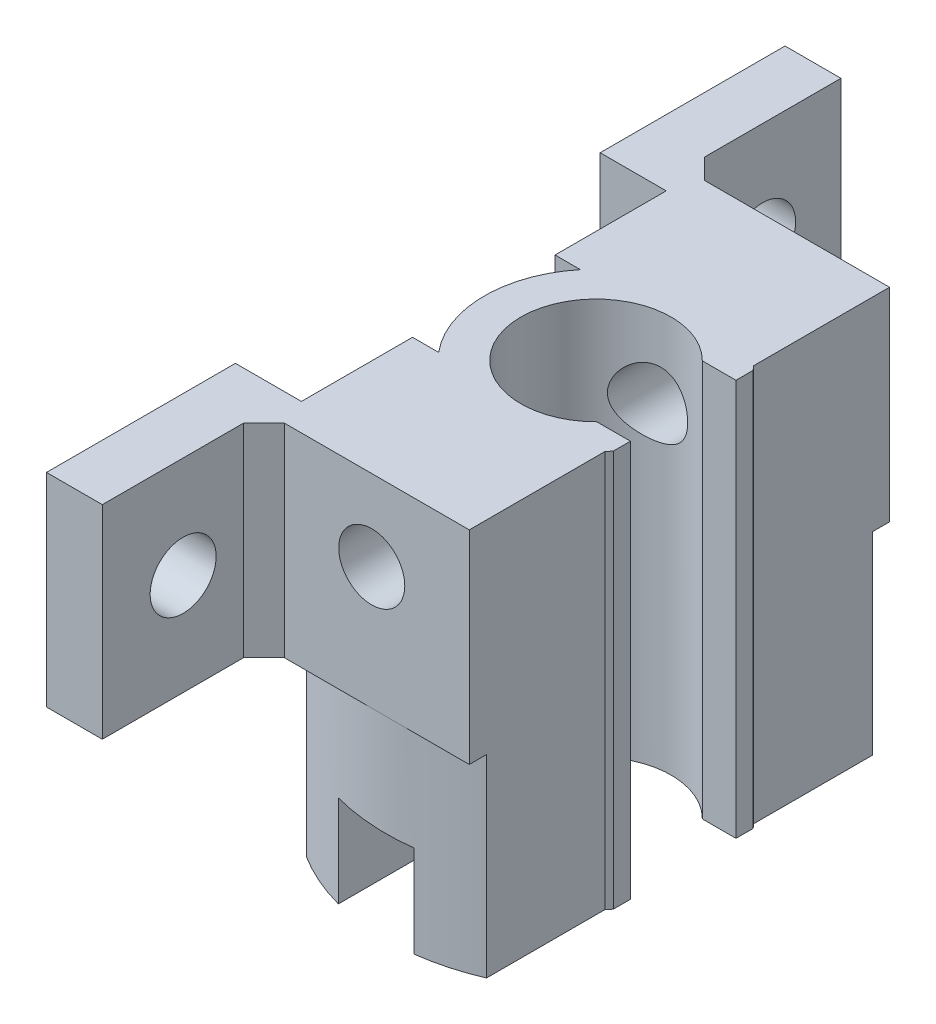
from build123d import *

# Parameters (mm, degrees)
SKETCH_1_R                = 20.68
SKETCH_1_R_2              = 9.68
EXTRUDE_1_DEPTH           = 116.68
SKETCH_11_W               = 27
SKETCH_11_H               = 150
CUT_EXTRUDE_3_DEPTH       = 40
SKETCH_13_W               = 10
SKETCH_13_H               = 128.345013401
CUT_EXTRUDE_7_DEPTH       = 42.68
SKETCH_15_W               = 8
SKETCH_15_H               = 68.68
CUT_EXTRUDE_9_DEPTH       = 48
SKETCH_16_W               = 15.549431524
SKETCH_16_H               = 20
SKETCH_16_W_2             = 15.459431524
EXTRUDE_4_DEPTH           = 19.2
SKETCH_17_W               = 19.20851187
SKETCH_17_H               = 14.03
CUT_EXTRUDE_10_DEPTH      = 20.2
SKETCH_18_R               = 9.59
CUT_EXTRUDE_11_DEPTH      = 117.68
SKETCH_21_R               = 2.985
CUT_EXTRUDE_12_DEPTH      = 55.2
SKETCH_24_R               = 20.59
SKETCH_24_R_2             = 9.59
EXTRUDE_2_DEPTH           = 55.2
CUT_EXTRUDE_13_DEPTH      = 55.2
SKETCH_26_W               = 10.00851187
SKETCH_26_H               = 41.68
CUT_EXTRUDE_15_DEPTH      = 55.2
SKETCH_27_W               = 10
SKETCH_27_H               = 40
CUT_EXTRUDE_16_DEPTH      = 55.2
SKETCH_28_W               = 44.880694938
SKETCH_28_H               = 9.608044066
CUT_EXTRUDE_17_DEPTH      = 12.2
SKETCH_35_W               = 13.53
SKETCH_35_H               = 20
EXTRUDE_10_DEPTH          = 15
EXTRUDE_11_DEPTH          = 15
SKETCH_37_W               = 9
SKETCH_37_H               = 20
EXTRUDE_12_DEPTH          = 20
SKETCH_38_W               = 9
SKETCH_38_H               = 20
EXTRUDE_13_DEPTH          = 20
SKETCH_42_R               = 2.985
CUT_EXTRUDE_21_DEPTH      = 20
CUT_EXTRUDE_23_DEPTH      = 129.465
SKETCH_45_W               = 3
SKETCH_45_H               = 20
EXTRUDE_14_DEPTH          = 30
SKETCH_46_W               = 3
SKETCH_46_H               = 20
EXTRUDE_15_DEPTH          = 30
SKETCH_47_W               = 33.078221107
SKETCH_47_H               = 20
EXTRUDE_16_DEPTH          = 50
SKETCH_48_W               = 30
SKETCH_48_H               = 20
EXTRUDE_17_DEPTH          = 50
SKETCH_50_W               = 50
SKETCH_50_H               = 20
EXTRUDE_18_DEPTH          = 1
SKETCH_51_W               = 50
SKETCH_51_H               = 20
EXTRUDE_19_DEPTH          = 1
SKETCH_52_W               = 53
SKETCH_52_H               = 14
CUT_EXTRUDE_24_DEPTH      = 129.465
SKETCH_53_W               = 53
SKETCH_53_H               = 14
CUT_EXTRUDE_25_DEPTH      = 129.465
SKETCH_54_W               = 40
SKETCH_54_H               = 73.27
CUT_EXTRUDE_26_DEPTH      = 129.465
SKETCH_56_W               = 13.00851187
SKETCH_56_H               = 20
EXTRUDE_21_DEPTH          = 3.08
SKETCH_58_W               = 44.672014854
SKETCH_58_H               = 95.939897673
CUT_EXTRUDE_28_DEPTH      = 90.76
SKETCH_59_R               = 9.7
CUT_EXTRUDE_29_DEPTH      = 40.048276961
SKETCH_60_W               = 6.504255935
SKETCH_60_H               = 76.35
CUT_EXTRUDE_30_DEPTH      = 40.048276961
CUT_EXTRUDE_32_DEPTH      = 20
SKETCH_64_W               = 16.20851187
SKETCH_64_H               = 0.09
EXTRUDE_22_DEPTH          = 20
SKETCH_65_W               = 3.495744065
SKETCH_65_H               = 3.26
CUT_EXTRUDE_33_DEPTH      = 40.048276961
SKETCH_66_W               = 3.495744065
SKETCH_66_H               = 1.776778893
SKETCH_66_W_2             = 3.503635083
SKETCH_66_H_2             = 1.775
EXTRUDE_23_DEPTH          = 20.2
SKETCH_68_W               = 6.504255935
SKETCH_68_H               = 3.66
CUT_EXTRUDE_34_DEPTH      = 20
SKETCH_69_R               = 2.985
CUT_EXTRUDE_35_DEPTH      = 7.504255935
SKETCH_70_R               = 2.985
CUT_EXTRUDE_36_DEPTH      = 17
SKETCH_71_W               = 18.595
SKETCH_71_H               = 20
SKETCH_71_W_2             = 18.195
SKETCH_71_H_2             = 20.0404814
EXTRUDE_24_DEPTH          = 10
SKETCH_72_R               = 3.05
CUT_EXTRUDE_37_DEPTH      = 17.495744065
SKETCH_73_W               = 4
SKETCH_73_H               = 15.42
CUT_EXTRUDE_39_DEPTH      = 40.048276961
SKETCH_74_W               = 4
SKETCH_74_H               = 15.91
CUT_EXTRUDE_40_DEPTH      = 40.048276961
EXTRUDE_25_DEPTH          = 20
SKETCH_77_W               = 7
SKETCH_77_H               = 72.69
CUT_EXTRUDE_41_DEPTH      = 40.048276961
SKETCH_78_R               = 3.25
CUT_EXTRUDE_42_DEPTH      = 87.1
SKETCH_79_R               = 3.25
CUT_EXTRUDE_43_DEPTH      = 10
CUT_EXTRUDE_43_DEPTH_BACK = 10
SKETCH_80_R               = 10.995
SKETCH_80_R_2             = 6.995
EXTRUDE_3_DEPTH           = 40
CUT_EXTRUDE_44_DEPTH      = 87.1
SKETCH_82_W               = 11.494274306
SKETCH_82_H               = 10.39
CUT_EXTRUDE_45_DEPTH      = 43
SKETCH_83_R               = 3.25
CUT_EXTRUDE_46_DEPTH      = 78
SKETCH_84_W               = 4.108929189
SKETCH_84_H               = 16.904278856
CUT_EXTRUDE_47_DEPTH      = 46
SKETCH_85_R               = 7.4
CUT_EXTRUDE_48_DEPTH      = 40.048276961


with BuildPart() as part:
    # 草圖1 → 伸長-薄件1 (new body)
    with BuildSketch(Plane(origin=(0, 0, 0), x_dir=(1, 0, 0), z_dir=(0, 1, 0))):
        Circle(SKETCH_1_R)
        Circle(SKETCH_1_R_2, mode=Mode.SUBTRACT)
    extrude(amount=EXTRUDE_1_DEPTH)

    # 草圖11 → 除料-伸長3 (cut)
    with BuildSketch(Plane(origin=(0, 116.68, 0), x_dir=(1, 0, 0), z_dir=(0, 1, 0))):
        with Locations((21.70851187, -44.235815192)):
            Rectangle(SKETCH_11_W, SKETCH_11_H)
    extrude(amount=-CUT_EXTRUDE_3_DEPTH, mode=Mode.SUBTRACT)

    # 草圖13 → 除料-伸長7 (cut, through all)
    with BuildSketch(Plane.XY.offset(21)):
        with Locations((-16, 58.612182466)):
            Rectangle(SKETCH_13_W, SKETCH_13_H)
    extrude(amount=-CUT_EXTRUDE_7_DEPTH, mode=Mode.SUBTRACT)

    # 草圖15 → 除料-伸長9 (cut)
    with BuildSketch(Plane.XY.offset(21)):
        with Locations((-1.395744065, 52.34)):
            Rectangle(SKETCH_15_W, SKETCH_15_H)
    extrude(amount=-CUT_EXTRUDE_9_DEPTH, mode=Mode.SUBTRACT)

    # 草圖16 → 填料-伸長4 (add)
    with BuildSketch(Plane(origin=(8.20851187, 0, 0), x_dir=(0, 0, -1), z_dir=(1, 0, 0))):
        with Locations((12.905284238, 106.68)):
            Rectangle(SKETCH_16_W, SKETCH_16_H)
        with Locations((-12.860284238, 106.68)):
            Rectangle(SKETCH_16_W_2, SKETCH_16_H)
    extrude(amount=-EXTRUDE_4_DEPTH)

    # 草圖17 → 除料-伸長10 (cut)
    with BuildSketch(Plane(origin=(0, 116.68, 0), x_dir=(1, 0, 0), z_dir=(0, 1, 0))):
        with Locations((-1.395744065, -0.045)):
            Rectangle(SKETCH_17_W, SKETCH_17_H)
    extrude(amount=-CUT_EXTRUDE_10_DEPTH, mode=Mode.SUBTRACT)

    # 草圖18 → 除料-伸長11 (cut, through all)
    with BuildSketch(Plane.XZ):
        Circle(SKETCH_18_R)
    extrude(amount=-CUT_EXTRUDE_11_DEPTH, mode=Mode.SUBTRACT)

    # 草圖21 → 除料-伸長12 (cut)
    with BuildSketch(Plane(origin=(0, 0, -20.68), x_dir=(-1, 0, 0), z_dir=(0, 0, -1))):
        with Locations((1.39148813, 108.73)):
            Circle(SKETCH_21_R)
    extrude(amount=-CUT_EXTRUDE_12_DEPTH, mode=Mode.SUBTRACT)

    # 草圖24 → 伸長-薄件2 (add)
    with BuildSketch(Plane.XZ):
        Circle(SKETCH_24_R)
        Circle(SKETCH_24_R_2, mode=Mode.SUBTRACT)
    extrude(amount=EXTRUDE_2_DEPTH)

    # 草圖25 → 除料-伸長13 (cut)
    with BuildSketch(Plane.XY.offset(21)):
        Polygon((-1.39148813, -11.785), (22.612379708, -11.785), (22.612379708, -63.873337429), (-22.749525245, -63.873337429), (-22.749525245, -11.785), align=None)
    extrude(amount=-CUT_EXTRUDE_13_DEPTH, mode=Mode.SUBTRACT)

    # 草圖26 → 除料-伸長15 (cut)
    with BuildSketch(Plane(origin=(0, 0, 0), x_dir=(1, 0, 0), z_dir=(0, 1, 0))):
        with Locations((-15.995744065, -0.16)):
            Rectangle(SKETCH_26_W, SKETCH_26_H)
    extrude(amount=-CUT_EXTRUDE_15_DEPTH, mode=Mode.SUBTRACT)

    # 草圖27 → 除料-伸長16 (cut)
    with BuildSketch(Plane(origin=(21, 0, 0), x_dir=(0, 0, -1), z_dir=(1, 0, 0))):
        with Locations((0, 41.68)):
            Rectangle(SKETCH_27_W, SKETCH_27_H)
    extrude(amount=-CUT_EXTRUDE_16_DEPTH, mode=Mode.SUBTRACT)

    # 草圖28 → 除料-伸長17 (cut)
    with BuildSketch(Plane(origin=(21, 0, 0), x_dir=(0, 0, -1), z_dir=(1, 0, 0))):
        Rectangle(SKETCH_28_W, SKETCH_28_H)
    extrude(amount=-CUT_EXTRUDE_17_DEPTH, mode=Mode.SUBTRACT)

    # 草圖35 → 填料-伸長10 (add)
    with BuildSketch(Plane.ZY.offset(10.99148813)):
        with Locations((13.825, 106.68)):
            Rectangle(SKETCH_35_W, SKETCH_35_H)
    extrude(amount=EXTRUDE_10_DEPTH)

    # 草圖36 → 填料-伸長11 (add)
    with BuildSketch(Plane.ZY.offset(10.99148813)):
        Polygon((-20.68, 116.68), (-6.97, 116.68), (-6.97, 96.48), (-20.68, 96.68), align=None)
    extrude(amount=EXTRUDE_11_DEPTH)

    # 草圖37 → 填料-伸長12 (add)
    with BuildSketch(Plane.XY.offset(20.59)):
        with Locations((-21.49148813, 106.68)):
            Rectangle(SKETCH_37_W, SKETCH_37_H)
    extrude(amount=EXTRUDE_12_DEPTH)

    # 草圖38 → 填料-伸長13 (add)
    with BuildSketch(Plane(origin=(0, 0, -20.68), x_dir=(-1, 0, 0), z_dir=(0, 0, -1))):
        with Locations((21.49148813, 106.68)):
            Rectangle(SKETCH_38_W, SKETCH_38_H)
    extrude(amount=EXTRUDE_13_DEPTH)

    # 草圖42 → 除料-伸長21 (cut)
    with BuildSketch(Plane(origin=(-16.99148813, 0, 0), x_dir=(0, 0, -1), z_dir=(1, 0, 0))):
        with Locations((30.68, 106.554418142)):
            Circle(SKETCH_42_R)
        with Locations((-30.395640125, 106.68)):
            Circle(SKETCH_42_R)
    extrude(amount=-CUT_EXTRUDE_21_DEPTH, mode=Mode.SUBTRACT)

    # 草圖43 → 除料-伸長23 (cut, through all)
    with BuildSketch(Plane(origin=(0, 116.68, 0), x_dir=(1, 0, 0), z_dir=(0, 1, 0))):
        Polygon((-11, 6.97), (-10.99148813, 20.68), (-10.99148813, 48.096794253), (-28.274756234, 48.096794253), (-28.274756234, -43.270506289), (-11, -43.270506289), align=None)
    extrude(amount=-CUT_EXTRUDE_23_DEPTH, mode=Mode.SUBTRACT)

    # 草圖45 → 填料-伸長14 (add)
    with BuildSketch(Plane.XY.offset(20.59)):
        with Locations((-9.5, 106.68)):
            Rectangle(SKETCH_45_W, SKETCH_45_H)
    extrude(amount=EXTRUDE_14_DEPTH)

    # 草圖46 → 填料-伸長15 (add)
    with BuildSketch(Plane(origin=(0, 0, -20.68), x_dir=(-1, 0, 0), z_dir=(0, 0, -1))):
        with Locations((9.49148813, 106.68)):
            Rectangle(SKETCH_46_W, SKETCH_46_H)
    extrude(amount=EXTRUDE_15_DEPTH)

    # 草圖47 → 填料-伸長16 (add)
    with BuildSketch(Plane.ZY.offset(11)):
        with Locations((34.050889447, 106.68)):
            Rectangle(SKETCH_47_W, SKETCH_47_H)
    extrude(amount=EXTRUDE_16_DEPTH)

    # 草圖48 → 填料-伸長17 (add)
    with BuildSketch(Plane.ZY.offset(10.99148813)):
        with Locations((-35.68, 106.68)):
            Rectangle(SKETCH_48_W, SKETCH_48_H)
    extrude(amount=EXTRUDE_17_DEPTH)

    # 草圖50 → 填料-伸長18 (add)
    with BuildSketch(Plane(origin=(0, 0, 17.511778893), x_dir=(-1, 0, 0), z_dir=(0, 0, -1))):
        with Locations((36, 106.68)):
            Rectangle(SKETCH_50_W, SKETCH_50_H)
    extrude(amount=EXTRUDE_18_DEPTH)

    # 草圖51 → 填料-伸長19 (add)
    with BuildSketch(Plane.XY.offset(-20.68)):
        with Locations((-35.99148813, 106.68)):
            Rectangle(SKETCH_51_W, SKETCH_51_H)
    extrude(amount=EXTRUDE_19_DEPTH)

    # 草圖52 → 除料-伸長24 (cut, through all)
    with BuildSketch(Plane(origin=(0, 116.68, 0), x_dir=(1, 0, 0), z_dir=(0, 1, 0))):
        with Locations((-34.49148813, 43.68)):
            Rectangle(SKETCH_52_W, SKETCH_52_H)
    extrude(amount=-CUT_EXTRUDE_24_DEPTH, mode=Mode.SUBTRACT)

    # 草圖53 → 除料-伸長25 (cut, through all)
    with BuildSketch(Plane(origin=(0, 116.68, 0), x_dir=(1, 0, 0), z_dir=(0, 1, 0))):
        with Locations((-34.5, -43.59)):
            Rectangle(SKETCH_53_W, SKETCH_53_H)
    extrude(amount=-CUT_EXTRUDE_25_DEPTH, mode=Mode.SUBTRACT)

    # 草圖54 → 除料-伸長26 (cut, through all)
    with BuildSketch(Plane(origin=(0, 116.68, 0), x_dir=(1, 0, 0), z_dir=(0, 1, 0))):
        with Locations((-41, 0.045)):
            Rectangle(SKETCH_54_W, SKETCH_54_H)
    extrude(amount=-CUT_EXTRUDE_26_DEPTH, mode=Mode.SUBTRACT)

    # 草圖56 → 填料-伸長21 (add)
    with BuildSketch(Plane(origin=(0, 0, -36.68), x_dir=(-1, 0, 0), z_dir=(0, 0, -1))):
        with Locations((14.495744065, 106.68)):
            Rectangle(SKETCH_56_W, SKETCH_56_H)
    extrude(amount=EXTRUDE_21_DEPTH)

    # 草圖58 → 除料-伸長28 (cut, through all)
    with BuildSketch(Plane.XY.offset(50)):
        with Locations((-0.234953045, 29.661774302)):
            Rectangle(SKETCH_58_W, SKETCH_58_H)
    extrude(amount=-CUT_EXTRUDE_28_DEPTH, mode=Mode.SUBTRACT)

    # 草圖59 → 除料-伸長29 (cut, through all)
    with BuildSketch(Plane.XZ.offset(-77.631723139)):
        Circle(SKETCH_59_R)
    extrude(amount=-CUT_EXTRUDE_29_DEPTH, mode=Mode.SUBTRACT)

    # 草圖60 → 除料-伸長30 (cut, through all)
    with BuildSketch(Plane(origin=(0, 116.68, 0), x_dir=(1, 0, 0), z_dir=(0, 1, 0))):
        with Locations((-17.747872032, 1.585)):
            Rectangle(SKETCH_60_W, SKETCH_60_H)
    extrude(amount=-CUT_EXTRUDE_30_DEPTH, mode=Mode.SUBTRACT)

    # 草圖61 → 除料-伸長32 (cut)
    with BuildSketch(Plane(origin=(0, 116.68, 0), x_dir=(1, 0, 0), z_dir=(0, 1, 0))):
        Polygon((1.92725193, -20.59), (1.92725193, -22.399121663), (-2.174190472, -21.421542421), (-2.174190472, -20.59), align=None)
    extrude(amount=-CUT_EXTRUDE_32_DEPTH, mode=Mode.SUBTRACT)

    # 草圖64 → 填料-伸長22 (add)
    with BuildSketch(Plane(origin=(0, 116.68, 0), x_dir=(1, 0, 0), z_dir=(0, 1, 0))):
        with Locations((0.104255935, -20.635)):
            Rectangle(SKETCH_64_W, SKETCH_64_H)
    extrude(amount=-EXTRUDE_22_DEPTH)

    # 草圖65 → 除料-伸長33 (cut, through all)
    with BuildSketch(Plane(origin=(0, 116.68, 0), x_dir=(1, 0, 0), z_dir=(0, 1, 0))):
        with Locations((-12.747872033, -18.141778893)):
            Rectangle(SKETCH_65_W, SKETCH_65_H)
    extrude(amount=-CUT_EXTRUDE_33_DEPTH, mode=Mode.SUBTRACT)

    # 草圖66 → 填料-伸長23 (add)
    with BuildSketch(Plane(origin=(0, 96.48, 0), x_dir=(1, 0, 0), z_dir=(0, 1, 0))):
        with Locations((-12.747872033, -18.883389447)):
            Rectangle(SKETCH_66_W, SKETCH_66_H)
        with Locations((-12.743926524, 18.7925)):
            Rectangle(SKETCH_66_W_2, SKETCH_66_H_2)
    extrude(amount=EXTRUDE_23_DEPTH)

    # 草圖68 → 除料-伸長34 (cut)
    with BuildSketch(Plane(origin=(0, 116.68, 0), x_dir=(1, 0, 0), z_dir=(0, 1, 0))):
        with Locations((-11.243616098, 37.93)):
            Rectangle(SKETCH_68_W, SKETCH_68_H)
    extrude(amount=-CUT_EXTRUDE_34_DEPTH, mode=Mode.SUBTRACT)

    # 草圖69 → 除料-伸長35 (cut, through all)
    with BuildSketch(Plane(origin=(-7.99148813, 0, 0), x_dir=(0, 0, -1), z_dir=(1, 0, 0))):
        with Locations((28.39, 106.68)):
            Circle(SKETCH_69_R)
        with Locations((-28.635, 106.68)):
            Circle(SKETCH_69_R)
    extrude(amount=-CUT_EXTRUDE_35_DEPTH, mode=Mode.SUBTRACT)

    # 草圖70 → 除料-伸長36 (cut, through all)
    with BuildSketch(Plane(origin=(0, 0, 20.59), x_dir=(-1, 0, 0), z_dir=(0, 0, -1))):
        with Locations((1.39148813, 108.73)):
            Circle(SKETCH_70_R)
    extrude(amount=-CUT_EXTRUDE_36_DEPTH, mode=Mode.SUBTRACT)

    # 草圖71 → 填料-伸長24 (add)
    with BuildSketch(Plane.ZY.offset(14.495744065)):
        with Locations((27.2925, 106.68)):
            Rectangle(SKETCH_71_W, SKETCH_71_H)
        with Locations((-27.0025, 106.6597593)):
            Rectangle(SKETCH_71_W_2, SKETCH_71_H_2)
    extrude(amount=EXTRUDE_24_DEPTH)

    # 草圖72 → 除料-伸長37 (cut, through all)
    with BuildSketch(Plane(origin=(-8, 0, 0), x_dir=(0, 0, -1), z_dir=(1, 0, 0))):
        with Locations((-28.635, 106.68)):
            Circle(SKETCH_72_R)
        with Locations((28.39, 106.68)):
            Circle(SKETCH_72_R)
    extrude(amount=-CUT_EXTRUDE_37_DEPTH, mode=Mode.SUBTRACT)

    # 草圖73 → 除料-伸長39 (cut, through all)
    with BuildSketch(Plane(origin=(0, 116.68, 0), x_dir=(1, 0, 0), z_dir=(0, 1, 0))):
        with Locations((-9.99148813, 28.39)):
            Rectangle(SKETCH_73_W, SKETCH_73_H)
    extrude(amount=-CUT_EXTRUDE_39_DEPTH, mode=Mode.SUBTRACT)

    # 草圖74 → 除料-伸長40 (cut, through all)
    with BuildSketch(Plane(origin=(0, 116.68, 0), x_dir=(1, 0, 0), z_dir=(0, 1, 0))):
        with Locations((-10, -28.635)):
            Rectangle(SKETCH_74_W, SKETCH_74_H)
    extrude(amount=-CUT_EXTRUDE_40_DEPTH, mode=Mode.SUBTRACT)

    # 草圖75 → 填料-伸長25 (add)
    with BuildSketch(Plane(origin=(0, 116.68, 0), x_dir=(1, 0, 0), z_dir=(0, 1, 0))):
        Polygon((-12, -20.68), (-12, -22.68), (-10, -20.68), align=None)
        Polygon((-11.99148813, 20.68), (-11.99148813, 22.68), (-9.99148813, 20.68), align=None)
    extrude(amount=-EXTRUDE_25_DEPTH)

    # 草圖77 → 除料-伸長41 (cut, through all)
    with BuildSketch(Plane(origin=(0, 116.68, 0), x_dir=(1, 0, 0), z_dir=(0, 1, 0))):
        with Locations((-20.995744065, -0.245)):
            Rectangle(SKETCH_77_W, SKETCH_77_H)
    extrude(amount=-CUT_EXTRUDE_41_DEPTH, mode=Mode.SUBTRACT)

    # 草圖78 → 除料-伸長42 (cut, through all)
    with BuildSketch(Plane.XY.offset(50)):
        with Locations((-1.39148813, 108.73)):
            Circle(SKETCH_78_R)
    extrude(amount=-CUT_EXTRUDE_42_DEPTH, mode=Mode.SUBTRACT)

    # 草圖79 → 除料-伸長43 (cut, two sides)
    with BuildSketch(Plane(origin=(-11.99148813, 0, 0), x_dir=(0, 0, -1), z_dir=(1, 0, 0))) as cut_extrude_43_sk:
        with Locations((28.39, 106.68)):
            Circle(SKETCH_79_R)
        with Locations((-28.635, 106.68)):
            Circle(SKETCH_79_R)
    extrude(amount=CUT_EXTRUDE_43_DEPTH, mode=Mode.SUBTRACT)
    extrude(cut_extrude_43_sk.sketch, amount=-CUT_EXTRUDE_43_DEPTH_BACK, mode=Mode.SUBTRACT)

    # 草圖80 → 伸長-薄件3 (add)
    with BuildSketch(Plane(origin=(0, 116.68, 0), x_dir=(1, 0, 0), z_dir=(0, 1, 0))):
        Circle(SKETCH_80_R)
        Circle(SKETCH_80_R_2, mode=Mode.SUBTRACT)
    extrude(amount=-EXTRUDE_3_DEPTH)

    # 草圖81 → 除料-伸長44 (cut, through all)
    with BuildSketch(Plane.XY.offset(50)):
        Polygon((8.20851187, 77.631723139), (-11, 77.631723139), (-10.995, 76.68), (10.995, 76.68), (10.995, 77.631723139), align=None)
    extrude(amount=-CUT_EXTRUDE_44_DEPTH, mode=Mode.SUBTRACT)

    # 草圖82 → 除料-伸長45 (cut)
    with BuildSketch(Plane(origin=(0, 116.68, 0), x_dir=(1, 0, 0), z_dir=(0, 1, 0))):
        with Locations((6.995, 0)):
            Rectangle(SKETCH_82_W, SKETCH_82_H)
    extrude(amount=-CUT_EXTRUDE_45_DEPTH, mode=Mode.SUBTRACT)

    # 草圖83 → 除料-伸長46 (cut)
    with BuildSketch(Plane.XY.offset(50)):
        with Locations((-1.39148813, 108.73)):
            Circle(SKETCH_83_R)
    extrude(amount=-CUT_EXTRUDE_46_DEPTH, mode=Mode.SUBTRACT)

    # 草圖84 → 除料-伸長47 (cut)
    with BuildSketch(Plane(origin=(0, 116.68, 0), x_dir=(1, 0, 0), z_dir=(0, 1, 0))):
        with Locations((10.635588866, -0.211738477)):
            Rectangle(SKETCH_84_W, SKETCH_84_H)
    extrude(amount=-CUT_EXTRUDE_47_DEPTH, mode=Mode.SUBTRACT)

    # 草圖85 → 除料-伸長48 (cut, through all)
    with BuildSketch(Plane(origin=(0, 116.68, 0), x_dir=(1, 0, 0), z_dir=(0, 1, 0))):
        Circle(SKETCH_85_R)
    extrude(amount=-CUT_EXTRUDE_48_DEPTH, mode=Mode.SUBTRACT)


solid = part.part
